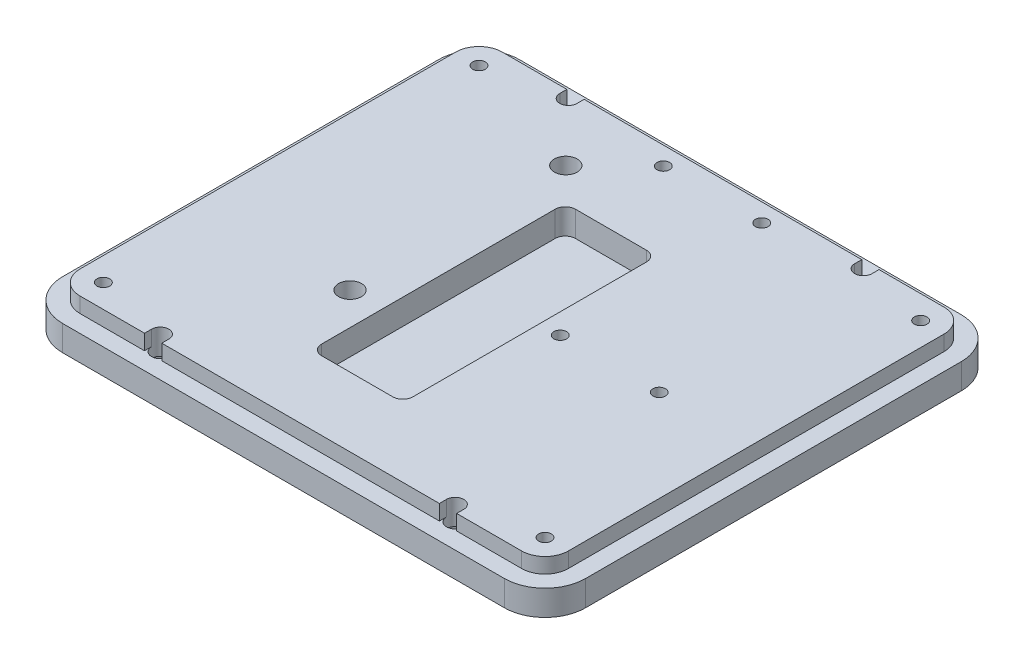
from build123d import *

# Parameters (mm, degrees)
SKETCH1_W                      = 103
SKETCH1_H                      = 90
BOSS_EXTRUDE1_DEPTH            = 8
FILLET1_R                      = 8
SKETCH7_OUTSIDE_W              = 132.402
SKETCH7_OUTSIDE_H              = 119.402
CUT_EXTRUDE2_DEPTH             = 3
M3X0_5_TAPPED_HOLE1_D          = 2.5
SKETCH15_W                     = 18
SKETCH15_H                     = 50
CUT_EXTRUDE3_DEPTH             = 5
FILLET3_R                      = 2
CBORE_FOR_M4_SHCS1_D           = 4.5
CBORE_FOR_M4_SHCS1_CBORE_D     = 8
CBORE_FOR_M4_SHCS1_CBORE_DEPTH = 4
CBORE_FOR_M3_SHCS2_D           = 3.4
CBORE_FOR_M3_SHCS2_CBORE_D     = 6.5
CBORE_FOR_M3_SHCS2_CBORE_DEPTH = 3
CUT_EXTRUDE4_DEPTH             = 3


with BuildPart() as part:
    # Sketch1 → Boss-Extrude1 (new body)
    with BuildSketch(Plane(origin=(0, 0, 0), x_dir=(1, 0, 0), z_dir=(0, 1, 0))):
        Rectangle(SKETCH1_W, SKETCH1_H)
    extrude(amount=BOSS_EXTRUDE1_DEPTH)

    # Fillet1
    fillet1_edges = [part.edges().sort_by_distance(p)[0] for p in [
        (51.5, 4, 45),
        (-51.5, 4, 45),
        (-51.5, 4, -45),
        (51.5, 4, -45),
    ]]
    fillet(fillet1_edges, radius=FILLET1_R)

    # Sketch7 outside → Cut-Extrude2 (cut)
    with BuildSketch(Plane(origin=(0, 8, 0), x_dir=(1, 0, 0), z_dir=(0, 1, 0))):
        Rectangle(SKETCH7_OUTSIDE_W, SKETCH7_OUTSIDE_H)
        with BuildLine():
            Line((-43.5, -41.6), (43.5, -41.6))
            ThreePointArc((43.5, -41.6), (46.752691193, -40.252691193), (48.1, -37))
            Line((48.1, -37), (48.1, 37))
            ThreePointArc((48.1, 37), (46.752691193, 40.252691193), (43.5, 41.6))
            Line((43.5, 41.6), (-43.5, 41.6))
            ThreePointArc((-43.5, 41.6), (-46.752691193, 40.252691193), (-48.1, 37))
            Line((-48.1, 37), (-48.1, -37))
            ThreePointArc((-48.1, -37), (-46.752691193, -40.252691193), (-43.5, -41.6))
        make_face(mode=Mode.SUBTRACT)
    extrude(amount=-CUT_EXTRUDE2_DEPTH, mode=Mode.SUBTRACT)

    # M3x0.5 Tapped Hole1 (through all)
    with Locations(Plane(origin=(0, 8, 0), x_dir=(1, 0, 0), z_dir=(0, 1, 0))):
        with Locations((-43.5, -37), (-43.5, 37), (43.5, 37), (43.5, -37), (-8.2, 38), (11.2, 38), (30, -1), (10.5, -1)):
            Hole(M3X0_5_TAPPED_HOLE1_D / 2)

    # Sketch15 → Cut-Extrude3 (cut)
    with BuildSketch(Plane(origin=(0, 8, 0), x_dir=(1, 0, 0), z_dir=(0, 1, 0))):
        with Locations((-2.5, -3)):
            Rectangle(SKETCH15_W, SKETCH15_H)
    extrude(amount=-CUT_EXTRUDE3_DEPTH, mode=Mode.SUBTRACT)

    # Fillet3
    fillet3_edges = [part.edges().sort_by_distance(p)[0] for p in [
        (-11.5, 5.5, 28),
        (-11.5, 5.5, -22),
        (6.5, 5.5, -22),
        (6.5, 5.5, 28),
    ]]
    fillet(fillet3_edges, radius=FILLET3_R)

    # CBORE for M4 SHCS1 (through all)
    with Locations(Plane(origin=(0, 0, 0), x_dir=(-1, 0, 0), z_dir=(0, -1, 0))):
        with Locations((17.9, -14), (17.9, 28.5)):
            CounterBoreHole(CBORE_FOR_M4_SHCS1_D / 2, CBORE_FOR_M4_SHCS1_CBORE_D / 2, CBORE_FOR_M4_SHCS1_CBORE_DEPTH)

    # CBORE for M3 SHCS2 (through all)
    with Locations(Plane(origin=(0, 0, 0), x_dir=(-1, 0, 0), z_dir=(0, -1, 0))):
        with Locations((29.087867966, -40.2), (-29, -40.2), (29.087867966, 40.2), (-29, 40.2)):
            CounterBoreHole(CBORE_FOR_M3_SHCS2_D / 2, CBORE_FOR_M3_SHCS2_CBORE_D / 2, CBORE_FOR_M3_SHCS2_CBORE_DEPTH)

    # Sketch21 → Cut-Extrude4 (cut)
    with BuildSketch(Plane(origin=(0, 8, 0), x_dir=(1, 0, 0), z_dir=(0, 1, 0))):
        with BuildLine():
            Line((-30.787867966, 40.2), (-30.787867966, 45))
            ThreePointArc((-30.787867966, 45), (-29.087867966, 46.7), (-27.387867966, 45))
            Line((-27.387867966, 45), (-27.387867966, 40.2))
            ThreePointArc((-27.387867966, 40.2), (-29.087867966, 38.5), (-30.787867966, 40.2))
        make_face()
        with BuildLine():
            Line((27.3, 40.2), (27.3, 45))
            ThreePointArc((27.3, 45), (29, 46.7), (30.7, 45))
            Line((30.7, 45), (30.7, 40.2))
            ThreePointArc((30.7, 40.2), (29, 38.5), (27.3, 40.2))
        make_face()
        with BuildLine():
            Line((-27.387867966, -40.2), (-27.387867966, -45))
            ThreePointArc((-27.387867966, -45), (-29.087867966, -46.7), (-30.787867966, -45))
            Line((-30.787867966, -45), (-30.787867966, -40.2))
            ThreePointArc((-30.787867966, -40.2), (-29.087867966, -38.5), (-27.387867966, -40.2))
        make_face()
        with BuildLine():
            Line((30.7, -40.2), (30.7, -45))
            ThreePointArc((30.7, -45), (29, -46.7), (27.3, -45))
            Line((27.3, -45), (27.3, -40.2))
            ThreePointArc((27.3, -40.2), (29, -38.5), (30.7, -40.2))
        make_face()
    extrude(amount=-CUT_EXTRUDE4_DEPTH, mode=Mode.SUBTRACT)


solid = part.part
